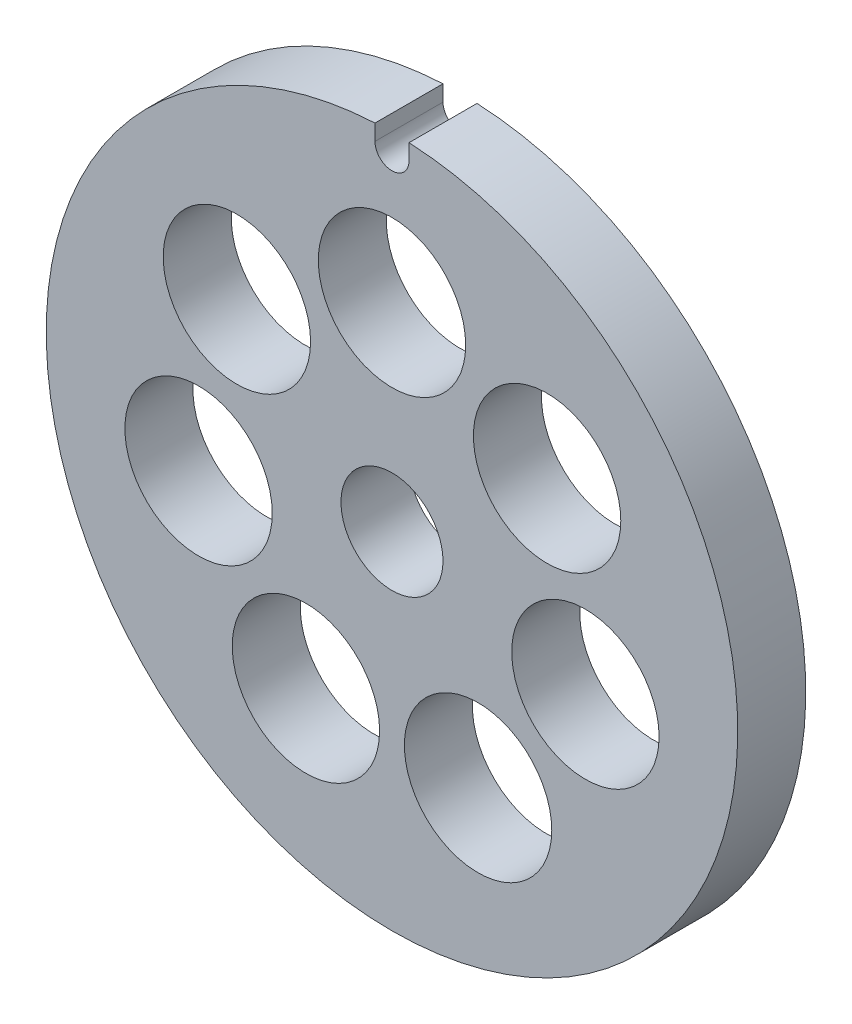
from build123d import *

# Parameters (mm, degrees)
SKETCH1_R           = 4.5
SKETCH1_R_2         = 6.5
BOSS_EXTRUDE1_DEPTH = 6


with BuildPart() as part:
    # Sketch1 → Boss-Extrude1 (new body)
    with BuildSketch(Plane.XY):
        with BuildLine():
            Line((-1.5, 29.063092423), (-1.5, 30.463092423))
            ThreePointArc((-1.5, 30.463092423), (0, -30.5), (1.5, 30.463092423))
            Line((1.5, 30.463092423), (1.5, 29.063092423))
            ThreePointArc((1.5, 29.063092423), (0, 27.563092423), (-1.5, 29.063092423))
        make_face()
        Circle(SKETCH1_R, mode=Mode.SUBTRACT)
        with Locations((0, 17.5)):
            Circle(SKETCH1_R_2, mode=Mode.SUBTRACT)
        with Locations((13.682050943, 10.911071533)):
            Circle(SKETCH1_R_2, mode=Mode.SUBTRACT)
        with Locations((17.061238463, -3.894116344)):
            Circle(SKETCH1_R_2, mode=Mode.SUBTRACT)
        with Locations((7.592965435, -15.766955188)):
            Circle(SKETCH1_R_2, mode=Mode.SUBTRACT)
        with Locations((-7.592965435, -15.766955188)):
            Circle(SKETCH1_R_2, mode=Mode.SUBTRACT)
        with Locations((-17.061238463, -3.894116344)):
            Circle(SKETCH1_R_2, mode=Mode.SUBTRACT)
        with Locations((-13.682050943, 10.911071533)):
            Circle(SKETCH1_R_2, mode=Mode.SUBTRACT)
    extrude(amount=BOSS_EXTRUDE1_DEPTH)


solid = part.part
